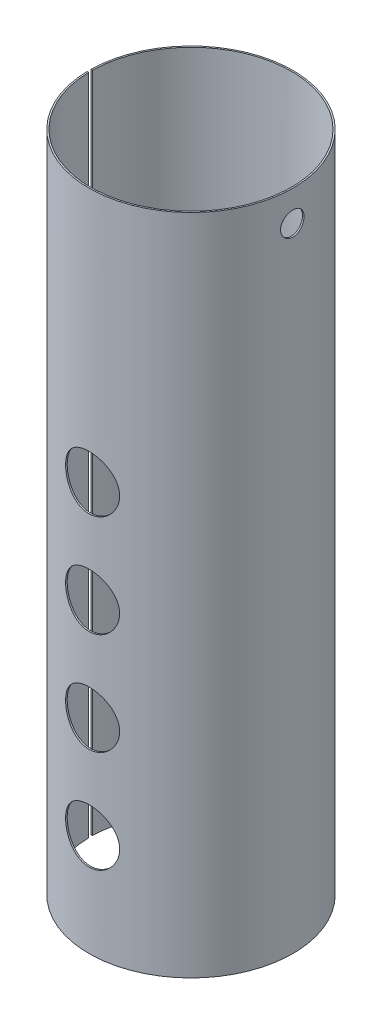
from build123d import *

# Parameters (mm, degrees)
SCHNITT_LINEAR_AUSTRAGEN1_REACH      = 102
SCHNITT_LINEAR_AUSTRAGEN1_END_RADIUS = 100
SKIZZE2_R                            = 26.5
SCHNITT_LINEAR_AUSTRAGEN2_REACH      = 102
SCHNITT_LINEAR_AUSTRAGEN2_END_RADIUS = 100
SKIZZE3_R                            = 11.5
SCHNITT_LINEAR_AUSTRAGEN3_REACH      = 102
SCHNITT_LINEAR_AUSTRAGEN3_END_RADIUS = 100
SKIZZE4_R                            = 14
SCHNITT_LINEAR_AUSTRAGEN4_DEPTH      = 651.0000001


with BuildPart() as part:
    # Skizze1 → Rotation-Dünn1 (revolve)
    with BuildSketch(Plane.XY):
        Polygon((-100, 0), (-100, 20), (-100, 30), (-100, 650), (-98.5, 650), (-98.5, 30), (-98.5, 20), (-98.5, 0), align=None)
    revolve(axis=Axis((0, 750, 0), (0, -1, 0)))

    # Schnitt-Linear austragen1: up to this cylinder (the profile starts inside it)
    schnitt_linear_austragen1_end = Plane(origin=(0, 250, 0), z_dir=(0, 1, 0)) * Cylinder(SCHNITT_LINEAR_AUSTRAGEN1_END_RADIUS, 705, mode=Mode.PRIVATE)
    # Skizze2 → Schnitt-Linear austragen1 (cut, up to the surface)
    with BuildSketch(Plane.XY, mode=Mode.PRIVATE) as schnitt_linear_austragen1_sk1:
        with Locations(Location((0, 100, 0), (0, 0, 180))):  # turned: the seam where the file's is
            Circle(SKIZZE2_R)
    schnitt_linear_austragen1_tool1 = extrude(schnitt_linear_austragen1_sk1.sketch, amount=SCHNITT_LINEAR_AUSTRAGEN1_REACH, mode=Mode.PRIVATE) & schnitt_linear_austragen1_end
    add(schnitt_linear_austragen1_tool1.solids().sort_by_distance((0, 100, 0))[0], mode=Mode.SUBTRACT)
    # Skizze2 → Schnitt-Linear austragen1 (cut, up to the surface)
    with BuildSketch(Plane.XY, mode=Mode.PRIVATE) as schnitt_linear_austragen1_sk2:
        with Locations(Location((0, 200, 0), (0, 0, 180))):  # turned: the seam where the file's is
            Circle(SKIZZE2_R)
    schnitt_linear_austragen1_tool2 = extrude(schnitt_linear_austragen1_sk2.sketch, amount=SCHNITT_LINEAR_AUSTRAGEN1_REACH, mode=Mode.PRIVATE) & schnitt_linear_austragen1_end
    add(schnitt_linear_austragen1_tool2.solids().sort_by_distance((0, 200, 0))[0], mode=Mode.SUBTRACT)
    # Skizze2 → Schnitt-Linear austragen1 (cut, up to the surface)
    with BuildSketch(Plane.XY, mode=Mode.PRIVATE) as schnitt_linear_austragen1_sk3:
        with Locations(Location((0, 300, 0), (0, 0, 180))):  # turned: the seam where the file's is
            Circle(SKIZZE2_R)
    schnitt_linear_austragen1_tool3 = extrude(schnitt_linear_austragen1_sk3.sketch, amount=SCHNITT_LINEAR_AUSTRAGEN1_REACH, mode=Mode.PRIVATE) & schnitt_linear_austragen1_end
    add(schnitt_linear_austragen1_tool3.solids().sort_by_distance((0, 300, 0))[0], mode=Mode.SUBTRACT)
    # Skizze2 → Schnitt-Linear austragen1 (cut, up to the surface)
    with BuildSketch(Plane.XY, mode=Mode.PRIVATE) as schnitt_linear_austragen1_sk4:
        with Locations(Location((0, 400, 0), (0, 0, 180))):  # turned: the seam where the file's is
            Circle(SKIZZE2_R)
    schnitt_linear_austragen1_tool4 = extrude(schnitt_linear_austragen1_sk4.sketch, amount=SCHNITT_LINEAR_AUSTRAGEN1_REACH, mode=Mode.PRIVATE) & schnitt_linear_austragen1_end
    add(schnitt_linear_austragen1_tool4.solids().sort_by_distance((0, 400, 0))[0], mode=Mode.SUBTRACT)

    # Schnitt-Linear austragen2: up to this cylinder (the profile starts inside it)
    schnitt_linear_austragen2_end = Plane(origin=(0, 620, 0), z_dir=(0, 1, 0)) * Cylinder(SCHNITT_LINEAR_AUSTRAGEN2_END_RADIUS, 405, mode=Mode.PRIVATE)
    # Skizze3 → Schnitt-Linear austragen2 (cut, up to the surface)
    with BuildSketch(Plane(origin=(0, 0, 0), x_dir=(0, 0, -1), z_dir=(1, 0, 0)), mode=Mode.PRIVATE) as schnitt_linear_austragen2_sk1:
        with Locations(Location((0, 620, 0), (0, 0, 180))):  # turned: the seam where the file's is
            Circle(SKIZZE3_R)
    schnitt_linear_austragen2_tool1 = extrude(schnitt_linear_austragen2_sk1.sketch, amount=SCHNITT_LINEAR_AUSTRAGEN2_REACH, mode=Mode.PRIVATE) & schnitt_linear_austragen2_end
    add(schnitt_linear_austragen2_tool1.solids().sort_by_distance((0, 620, 0))[0], mode=Mode.SUBTRACT)

    # Schnitt-Linear austragen3: up to this cylinder (the profile starts inside it)
    schnitt_linear_austragen3_end = Plane(origin=(0, 250, 0), z_dir=(0, 1, 0)) * Cylinder(SCHNITT_LINEAR_AUSTRAGEN3_END_RADIUS, 705, mode=Mode.PRIVATE)
    # Skizze4 → Schnitt-Linear austragen3 (cut, up to the surface)
    with BuildSketch(Plane.XY, mode=Mode.PRIVATE) as schnitt_linear_austragen3_sk1:
        with Locations((0, 400)):
            Circle(SKIZZE4_R)
    schnitt_linear_austragen3_tool1 = extrude(schnitt_linear_austragen3_sk1.sketch, amount=-SCHNITT_LINEAR_AUSTRAGEN3_REACH, mode=Mode.PRIVATE) & schnitt_linear_austragen3_end
    add(schnitt_linear_austragen3_tool1.solids().sort_by_distance((0, 400, 0))[0], mode=Mode.SUBTRACT)
    # Skizze4 → Schnitt-Linear austragen3 (cut, up to the surface)
    with BuildSketch(Plane.XY, mode=Mode.PRIVATE) as schnitt_linear_austragen3_sk2:
        with Locations((0, 300)):
            Circle(SKIZZE4_R)
    schnitt_linear_austragen3_tool2 = extrude(schnitt_linear_austragen3_sk2.sketch, amount=-SCHNITT_LINEAR_AUSTRAGEN3_REACH, mode=Mode.PRIVATE) & schnitt_linear_austragen3_end
    add(schnitt_linear_austragen3_tool2.solids().sort_by_distance((0, 300, 0))[0], mode=Mode.SUBTRACT)
    # Skizze4 → Schnitt-Linear austragen3 (cut, up to the surface)
    with BuildSketch(Plane.XY, mode=Mode.PRIVATE) as schnitt_linear_austragen3_sk3:
        with Locations((0, 200)):
            Circle(SKIZZE4_R)
    schnitt_linear_austragen3_tool3 = extrude(schnitt_linear_austragen3_sk3.sketch, amount=-SCHNITT_LINEAR_AUSTRAGEN3_REACH, mode=Mode.PRIVATE) & schnitt_linear_austragen3_end
    add(schnitt_linear_austragen3_tool3.solids().sort_by_distance((0, 200, 0))[0], mode=Mode.SUBTRACT)
    # Skizze4 → Schnitt-Linear austragen3 (cut, up to the surface)
    with BuildSketch(Plane.XY, mode=Mode.PRIVATE) as schnitt_linear_austragen3_sk4:
        with Locations((0, 100)):
            Circle(SKIZZE4_R)
    schnitt_linear_austragen3_tool4 = extrude(schnitt_linear_austragen3_sk4.sketch, amount=-SCHNITT_LINEAR_AUSTRAGEN3_REACH, mode=Mode.PRIVATE) & schnitt_linear_austragen3_end
    add(schnitt_linear_austragen3_tool4.solids().sort_by_distance((0, 100, 0))[0], mode=Mode.SUBTRACT)

    # Skizze5 → Schnitt-Linear austragen4 (cut, through all)
    with BuildSketch(Plane(origin=(0, 0, 0), x_dir=(1, 0, 0), z_dir=(0, 1, 0))):
        Polygon((-101.019134301, 2), (0, 0), (-101.019134301, -2), align=None)
    extrude(amount=SCHNITT_LINEAR_AUSTRAGEN4_DEPTH, mode=Mode.SUBTRACT)


solid = part.part
